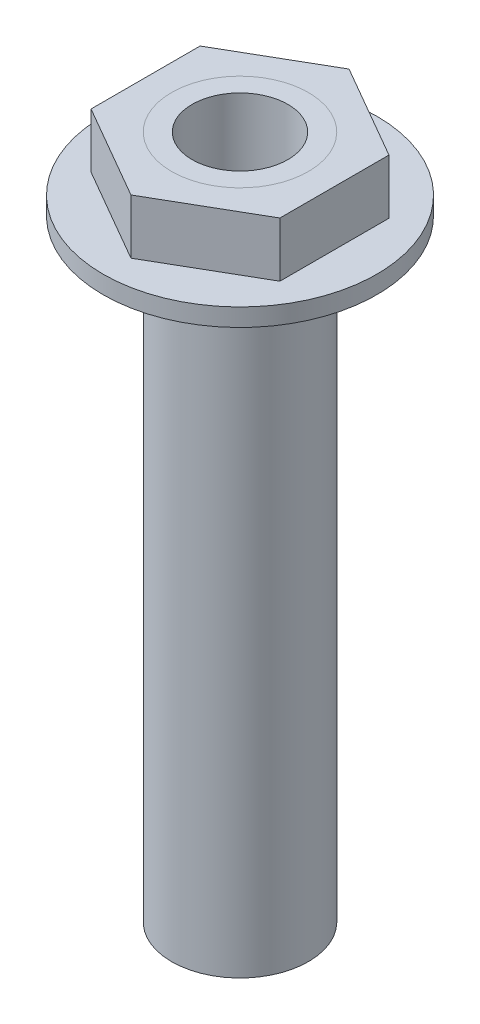
from build123d import *

# Parameters (mm, degrees)
SKETCH1_R           = 5
SKETCH1_R_2         = 3.5
BOSS_EXTRUDE1_DEPTH = 50
SKETCH2_R           = 5
BOSS_EXTRUDE2_DEPTH = 4
SKETCH3_R           = 10
SKETCH3_R_2         = 5
BOSS_EXTRUDE3_DEPTH = 1.3


with BuildPart() as part:
    # Sketch1 → Boss-Extrude1 (new body)
    with BuildSketch(Plane(origin=(0, 0, 0), x_dir=(1, 0, 0), z_dir=(0, 1, 0))):
        Circle(SKETCH1_R)
        Circle(SKETCH1_R_2, mode=Mode.SUBTRACT)
    extrude(amount=BOSS_EXTRUDE1_DEPTH)


with BuildPart() as body_2:
    # Sketch2 → Boss-Extrude2 (new body)
    with BuildSketch(Plane(origin=(0, 50, 0), x_dir=(1, 0, 0), z_dir=(0, 1, 0))):
        Polygon((0, 7.967433715), (-6.9, 3.983716857), (-6.9, -3.983716857), (0, -7.967433715), (6.9, -3.983716857), (6.9, 3.983716857), align=None)
        Circle(SKETCH2_R, mode=Mode.SUBTRACT)
    extrude(amount=-BOSS_EXTRUDE2_DEPTH)


with BuildPart() as body_3:
    # Sketch3 → Boss-Extrude3 (new body)
    with BuildSketch(Plane.XZ.offset(-46)):
        Circle(SKETCH3_R)
        Circle(SKETCH3_R_2, mode=Mode.SUBTRACT)
    extrude(amount=BOSS_EXTRUDE3_DEPTH)


solid = Compound([part.part, body_2.part, body_3.part])
